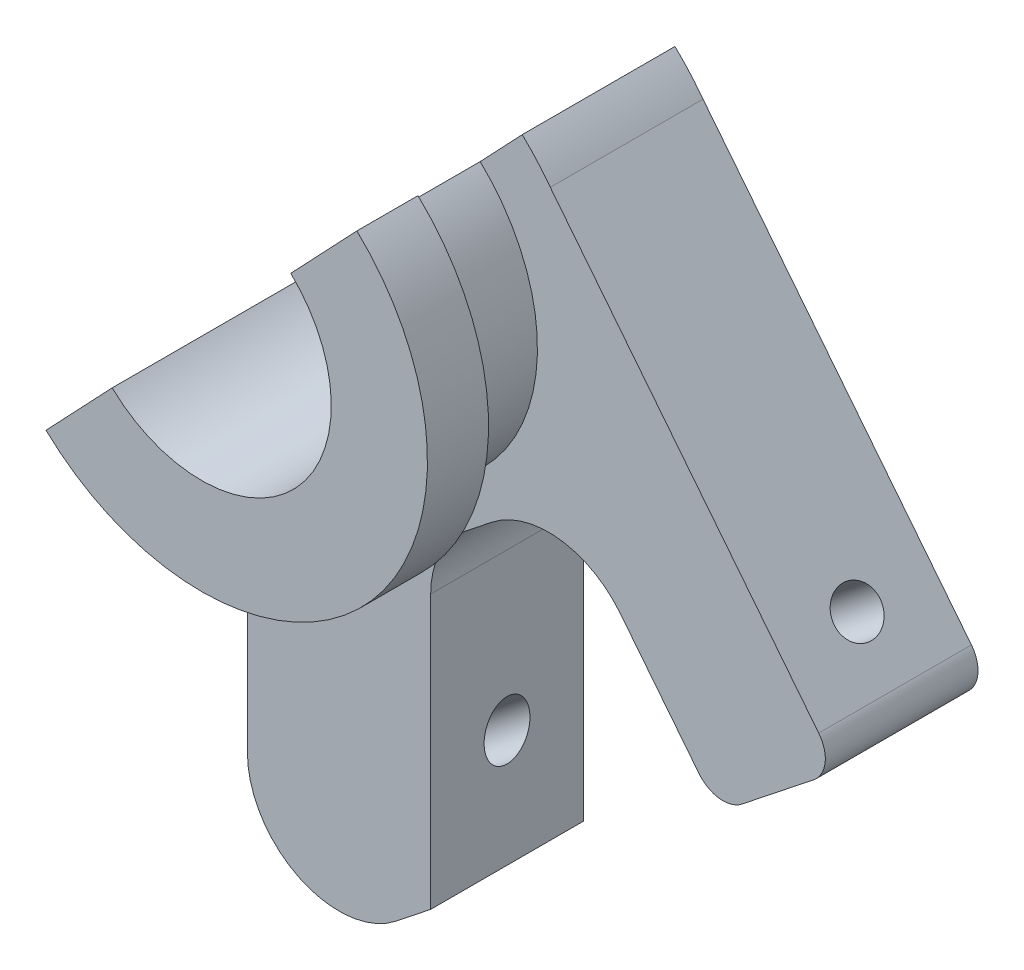
from build123d import *

# Parameters (mm, degrees)
P_IDAT_VYSUNUT_M1_DEPTH  = 5
SKICA2_R                 = 6
SKICA2_R_2               = 4.25
P_IDAT_VYSUNUT_M2_DEPTH  = 3
SKICA3_R                 = 7.399081898
SKICA3_R_2               = 4.25
P_IDAT_VYSUNUT_M3_DEPTH  = 2
ODEBRAT_VYSUNUT_M1_DEPTH = 12
SKICA5_R                 = 0.75
ODEBRAT_VYSUNUT_M2_DEPTH = 22
ODEBRAT_VYSUNUT_M3_DEPTH = 22
ZAOBLIT1_R               = 3
ZAOBLIT2_R               = 1


with BuildPart() as part:
    # Skica1 → Přidat vysunutím1 (new body)
    with BuildSketch(Plane.XY):
        with BuildLine():
            ThreePointArc((4.25, 0), (1.26615959, -4.057011202), (-3.495571714, -2.417328772))
            Line((-3.495571714, -2.417328772), (-3.495571714, -22.417328772))
            Line((-3.495571714, -22.417328772), (2.504428286, -17.65904484))
            Line((2.504428286, -17.65904484), (2.504428286, -7.266994767))
            Line((2.504428286, -7.266994767), (6.852381906, -3.818861792))
            Line((6.852381906, -3.818861792), (11.911787503, -10.198563806))
            Line((11.911787503, -10.198563806), (15.829382947, -7.09172523))
            Line((15.829382947, -7.09172523), (6.421160578, 4.771655566))
            ThreePointArc((6.421160578, 4.771655566), (5.746609385, 5.565651855), (4.974594852, 6.26525387))
            Line((4.974594852, 6.26525387), (1.66035906, 3.912250988))
            ThreePointArc((1.66035906, 3.912250988), (3.543940322, 2.345844623), (4.25, 0))
        make_face()
    extrude(amount=P_IDAT_VYSUNUT_M1_DEPTH)

    # Skica2 → Přidat vysunutím2 (add)
    with BuildSketch(Plane.XY.offset(5)):
        with Locations(Location((0, 0, 0), (0, 0, 234.366710991))):
            Circle(SKICA2_R)
        with Locations(Location((0, 0, 0), (0, 0, 214.665420921))):
            Circle(SKICA2_R_2, mode=Mode.SUBTRACT)
    extrude(amount=P_IDAT_VYSUNUT_M2_DEPTH)

    # Skica3 → Přidat vysunutím3 (add)
    with BuildSketch(Plane.XY.offset(8)):
        Circle(SKICA3_R)
        with Locations(Location((0, 0, 0), (0, 0, 214.665420921))):
            Circle(SKICA3_R_2, mode=Mode.SUBTRACT)
    extrude(amount=P_IDAT_VYSUNUT_M3_DEPTH)

    # Skica4 → Odebrat vysunutím1 (cut)
    with BuildSketch(Plane.XY.offset(10)):
        Polygon((7.922687554, 8.36122904), (-6.923828501, -7.307080525), (-16.64765112, 7.717248389), align=None)
    extrude(amount=-ODEBRAT_VYSUNUT_M1_DEPTH, mode=Mode.SUBTRACT)

    # Skica5 → Odebrat vysunutím2 (cut)
    with BuildSketch(Plane(origin=(6.265061416, 4.968490178, 0), x_dir=(0, 0, -1), z_dir=(0.7835190888567162, 0.6213677151229708, 0))):
        with Locations(Location((-2.5, -12.392369605, 0), (0, 0, 90))):
            Circle(SKICA5_R)
    extrude(amount=-ODEBRAT_VYSUNUT_M2_DEPTH, mode=Mode.SUBTRACT)

    # Skica7 → Odebrat vysunutím3 (cut)
    with BuildSketch(Plane.XY.offset(5)):
        with BuildLine():
            Line((-3.495571714, -22.417328772), (1.368531431, -18.559864799))
            ThreePointArc((1.368531431, -18.559864799), (-1.800885961, -18.910447054), (-3.495571714, -16.209307532))
            Line((-3.495571714, -16.209307532), (-3.495571714, -22.417328772))
        make_face()
    extrude(amount=-ODEBRAT_VYSUNUT_M3_DEPTH, mode=Mode.SUBTRACT)

    # Zaoblit1
    zaoblit1_edges = [part.edges().sort_by_distance(p)[0] for p in [
        (6.852381906, -3.818861792, 2.5),
        (2.504428286, -7.266994767, 2.5),
    ]]
    fillet(zaoblit1_edges, radius=ZAOBLIT1_R)

    # Zaoblit2
    zaoblit2_edges = [part.edges().sort_by_distance(p)[0] for p in [
        (15.829382947, -7.09172523, 2.5),
        (11.911787503, -10.198563806, 2.5),
    ]]
    fillet(zaoblit2_edges, radius=ZAOBLIT2_R)


solid = part.part
